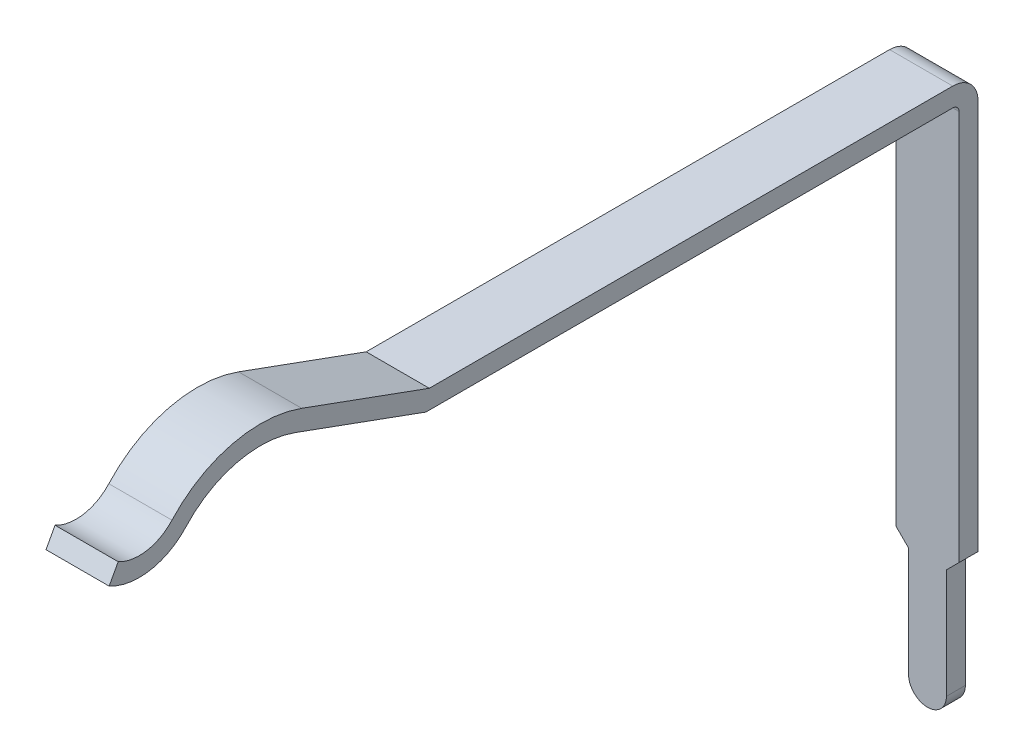
from build123d import *

# Parameters (mm, degrees)
EXTRUDE_THIN1_DEPTH = 0.5
CUT_EXTRUDE1_DEPTH  = 15.76


with BuildPart() as part:
    # Sketch1 → Extrude-Thin1 (new body, symmetric)
    with BuildSketch(Plane(origin=(0, 0, 0), x_dir=(0, 0, -1), z_dir=(1, 0, 0))):
        with BuildLine():
            ThreePointArc((1, 0.121157255), (1.643863846, 0.014001181), (2.216684029, 0.326923077))
            ThreePointArc((2.216684029, 0.326923077), (3.017058298, 0.803497877), (3.947232229, 0.753508193))
            Line((3.947232229, 0.753508193), (6.017478976, 0))
            Line((6.017478976, 0), (14.36, 0))
            ThreePointArc((14.36, 0), (14.430710678, -0.029289322), (14.46, -0.1))
            Line((14.46, -0.1), (14.46, -8.52))
            Line((14.46, -8.52), (14.76, -8.52))
            Line((14.76, -8.52), (14.76, -0.1))
            ThreePointArc((14.76, -0.1), (14.642842712, 0.182842712), (14.36, 0.3))
            Line((14.36, 0.3), (6.07037707, 0.3))
            Line((6.07037707, 0.3), (4.049838272, 1.035415979))
            ThreePointArc((4.049838272, 1.035415979), (2.945256729, 1.094778729), (1.994812285, 0.528846154))
            ThreePointArc((1.994812285, 0.528846154), (1.593838156, 0.309800827), (1.143133464, 0.384810078))
            Line((1.143133464, 0.384810078), (1, 0.121157255))
        make_face()
    extrude(amount=EXTRUDE_THIN1_DEPTH, both=True)

    # Sketch2 → Cut-Extrude1 (cut, through all)
    with BuildSketch(Plane.XY):
        with BuildLine():
            Line((-0.3, -8.22), (-0.3, -6.485265009))
            Line((-0.3, -6.485265009), (-0.5, -6.285265009))
            Line((-0.5, -6.285265009), (-0.5, -9.22))
            Line((-0.5, -9.22), (0.5, -9.22))
            Line((0.5, -9.22), (0.5, -6.285265009))
            Line((0.5, -6.285265009), (0.3, -6.485265009))
            Line((0.3, -6.485265009), (0.3, -8.22))
            ThreePointArc((0.3, -8.22), (0, -8.52), (-0.3, -8.22))
        make_face()
    extrude(amount=-CUT_EXTRUDE1_DEPTH, mode=Mode.SUBTRACT)


solid = part.part
